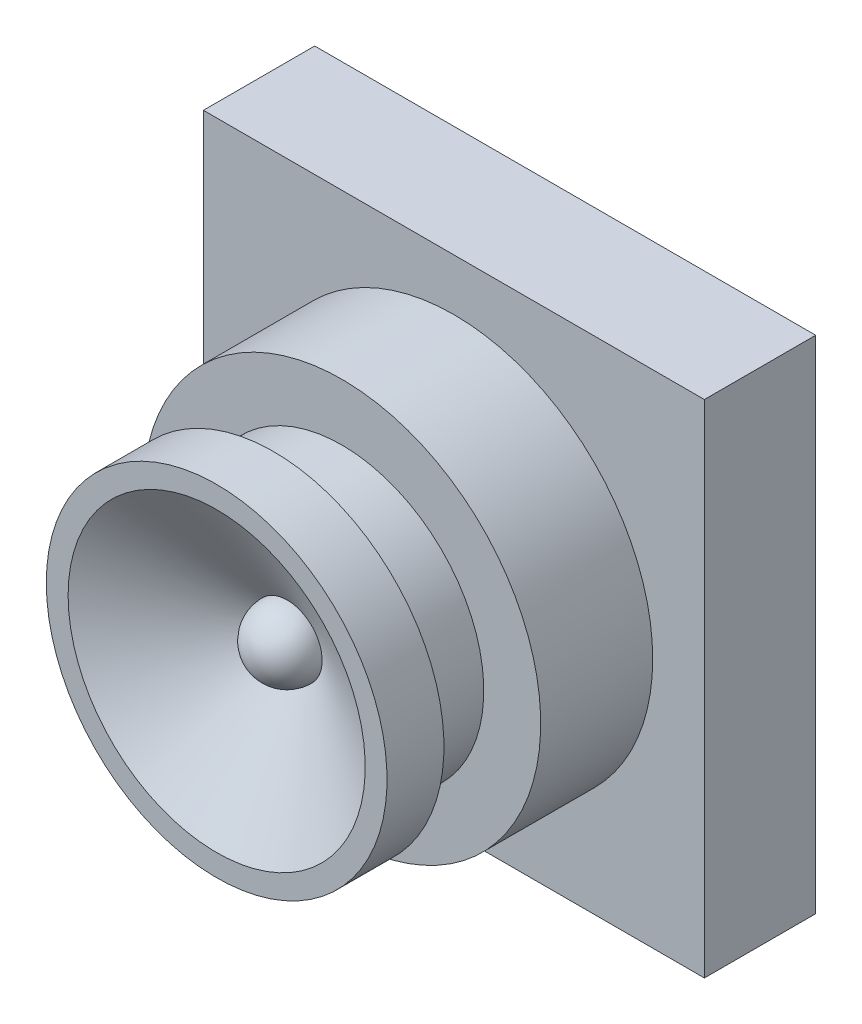
from build123d import *

# Parameters (mm, degrees)
ESQUISSE1_W      = 18
ESQUISSE1_H      = 18
EXTRUSION1_DEPTH = 4


with BuildPart() as part:
    # Esquisse1 → Extrusion1 (new body)
    with BuildSketch(Plane.XY):
        Rectangle(ESQUISSE1_W, ESQUISSE1_H)
    extrude(amount=EXTRUSION1_DEPTH)

    # Esquisse2 → Révolution1 (revolve)
    with BuildSketch(Plane(origin=(0, 0, 0), x_dir=(1, 0, 0), z_dir=(0, 1, 0))):
        with BuildLine():
            Line((0, -4), (-7.143680684, -4))
            Line((-7.143680684, -4), (-7.143680684, -8.024672755))
            Line((-7.143680684, -8.024672755), (-5.098733923, -8.024672755))
            Line((-5.098733923, -8.024672755), (-5.098733923, -9.987821645))
            Line((-5.098733923, -9.987821645), (-4.553414787, -9.987821645))
            Line((-4.553414787, -9.987821645), (-4.553414787, -10.478608868))
            Line((-4.553414787, -10.478608868), (-6.121207304, -10.478608868))
            Line((-6.121207304, -10.478608868), (-6.121207304, -12.523555628))
            Line((-6.121207304, -12.523555628), (-5.337311045, -12.523555628))
            Line((-5.337311045, -12.523555628), (-1.254234013, -9.987821645))
            ThreePointArc((-1.254234013, -9.987821645), (-0.889700858, -10.88151551), (0, -11.255688637))
            Line((0, -11.255688637), (0, -4))
        make_face()
    revolve(axis=Axis((0, 0, 0), (0, 0, 1)))


solid = part.part
